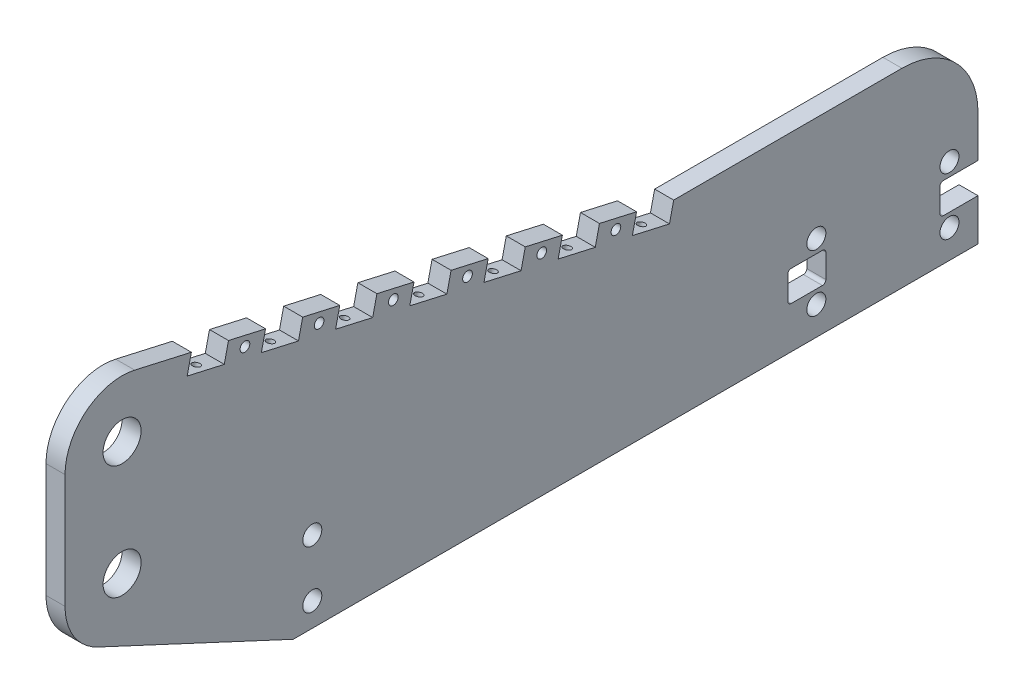
from build123d import *

# Parameters (mm, degrees)
SKETCH1_R           = 12.7
BOSS_EXTRUDE1_DEPTH = 12.7
SKETCH2_R           = 6.35
CUT_EXTRUDE1_DEPTH  = 13.7
SKETCH3_R           = 6.35
CUT_EXTRUDE2_DEPTH  = 13.7
SKETCH4_W           = 25.4
SKETCH4_H           = 20.32
CUT_EXTRUDE3_DEPTH  = 13.7
FILLET1_R           = 2.286
CUT_EXTRUDE4_DEPTH  = 13.7
SKETCH6_R           = 3.2385
CUT_EXTRUDE5_DEPTH  = 13.7
SKETCH7_R           = 2.5527
CUT_EXTRUDE6_DEPTH  = 25.4
SKETCH8_R           = 5.08
CUT_EXTRUDE7_DEPTH  = 6.35
FILLET2_R           = 50.8
CUT_EXTRUDE9_DEPTH  = 6.35
BOSS_EXTRUDE2_DEPTH = 3.81


with BuildPart() as part:
    # Sketch1 → Boss-Extrude1 (new body)
    with BuildSketch(Plane(origin=(0, 0, 0), x_dir=(0, 0, -1), z_dir=(1, 0, 0))):
        with BuildLine():
            ThreePointArc((8.42580134, 113.356639673), (-23.775901339, 105.971068431), (-38.1, 76.2))
            Line((-38.1, 76.2), (-38.1, 0))
            ThreePointArc((-38.1, 0), (-32.127559007, -20.479989069), (-16.082679671, -34.539215605))
            Line((-16.082679671, -34.539215605), (114.3, -95.25))
            Line((114.3, -95.25), (571.5, -95.25))
            Line((571.5, -95.25), (571.5, 31.75))
            Line((571.5, 31.75), (368.3, 31.75))
            Line((368.3, 31.75), (8.42580134, 113.356639673))
        make_face()
        with Locations((0, 76.2)):
            Circle(SKETCH1_R, mode=Mode.SUBTRACT)
        Circle(SKETCH1_R, mode=Mode.SUBTRACT)
    extrude(amount=BOSS_EXTRUDE1_DEPTH)

    # Sketch2 → Cut-Extrude1 (cut, through all)
    with BuildSketch(Plane(origin=(12.7, 0, 0), x_dir=(0, 0, -1), z_dir=(1, 0, 0))):
        with Locations((552.45, -38.1)):
            Circle(SKETCH2_R)
        with Locations((463.55, -38.1)):
            Circle(SKETCH2_R)
        with Locations((463.55, -76.2)):
            Circle(SKETCH2_R)
        with Locations((552.45, -76.2)):
            Circle(SKETCH2_R)
    extrude(amount=-CUT_EXTRUDE1_DEPTH, mode=Mode.SUBTRACT)

    # Sketch3 → Cut-Extrude2 (cut, through all)
    with BuildSketch(Plane(origin=(12.7, 0, 0), x_dir=(0, 0, -1), z_dir=(1, 0, 0))):
        with Locations((127, -41.275)):
            Circle(SKETCH3_R)
        with Locations((127, -79.375)):
            Circle(SKETCH3_R)
    extrude(amount=-CUT_EXTRUDE2_DEPTH, mode=Mode.SUBTRACT)

    # Sketch4 → Cut-Extrude3 (cut, through all)
    with BuildSketch(Plane(origin=(12.7, 0, 0), x_dir=(0, 0, -1), z_dir=(1, 0, 0))):
        with Locations((558.8, -57.15)):
            Rectangle(SKETCH4_W, SKETCH4_H)
        with Locations((457.2, -57.15)):
            Rectangle(SKETCH4_W, SKETCH4_H)
    extrude(amount=-CUT_EXTRUDE3_DEPTH, mode=Mode.SUBTRACT)

    # Fillet1
    fillet1_edges = [part.edges().sort_by_distance(p)[0] for p in [
        (6.35, -67.31, -546.1),
        (6.35, -46.99, -546.1),
        (6.35, -67.31, -444.5),
        (6.35, -46.99, -444.5),
        (6.35, -46.99, -469.9),
        (6.35, -67.31, -469.9),
    ]]
    fillet(fillet1_edges, radius=FILLET1_R)

    # Sketch5 → Cut-Extrude4 (cut, through all)
    with BuildSketch(Plane(origin=(12.7, 0, 0), x_dir=(0, 0, -1), z_dir=(1, 0, 0))):
        Polygon((368.3, 31.75), (343.528906885, 37.367200893), (340.720306438, 24.981654336), (365.491399553, 19.364453442), align=None)
        Polygon((293.986720654, 48.60160268), (291.178120208, 36.216056122), (315.949213323, 30.598855229), (318.757813769, 42.984401786), align=None)
        Polygon((244.444534424, 59.836004466), (241.635933977, 47.450457908), (266.407027092, 41.833257015), (269.215627539, 54.218803573), align=None)
        Polygon((194.902348193, 71.070406253), (192.093747747, 58.684859695), (216.864840862, 53.067658802), (219.673441308, 65.453205359), align=None)
        Polygon((145.360161963, 82.304808039), (142.551561516, 69.919261481), (167.322654631, 64.302060588), (170.131255078, 76.687607146), align=None)
        Polygon((95.817975732, 93.539209825), (93.009375285, 81.153663268), (117.780468401, 75.536462375), (120.589068847, 87.922008932), align=None)
        Polygon((46.275789502, 104.773611612), (43.467189055, 92.388065054), (68.23828217, 86.770864161), (71.046882617, 99.156410719), align=None)
    extrude(amount=-CUT_EXTRUDE4_DEPTH, mode=Mode.SUBTRACT)

    # Sketch6 → Cut-Extrude5 (cut, through all)
    with BuildSketch(Plane(origin=(12.7, 0, 0), x_dir=(0, 0, -1), z_dir=(1, 0, 0))):
        with Locations((329.739060104, 33.983028061)):
            Circle(SKETCH6_R)
        with Locations((280.196873873, 45.217429847)):
            Circle(SKETCH6_R)
        with Locations((230.654687643, 56.451831634)):
            Circle(SKETCH6_R)
        with Locations((181.112501412, 67.68623342)):
            Circle(SKETCH6_R)
        with Locations((131.570315182, 78.920635207)):
            Circle(SKETCH6_R)
        with Locations((82.028128951, 90.155036993)):
            Circle(SKETCH6_R)
    extrude(amount=-CUT_EXTRUDE5_DEPTH, mode=Mode.SUBTRACT)

    # Sketch7 → Cut-Extrude6 (cut)
    with BuildSketch(Plane(origin=(0, 97.244367225, -22.051555977), x_dir=(1, 0, 0), z_dir=(0, 0.975239886, -0.221149641))):
        with Locations((6.35, 339.459349055)):
            Circle(SKETCH7_R)
        with Locations((6.35, 288.659349055)):
            Circle(SKETCH7_R)
        with Locations((6.35, 237.859349055)):
            Circle(SKETCH7_R)
        with Locations((6.35, 187.059349055)):
            Circle(SKETCH7_R)
        with Locations((6.35, 136.259349055)):
            Circle(SKETCH7_R)
        with Locations((6.35, 85.459349055)):
            Circle(SKETCH7_R)
        with Locations((6.35, 34.659349055)):
            Circle(SKETCH7_R)
    extrude(amount=-CUT_EXTRUDE6_DEPTH, mode=Mode.SUBTRACT)

    # Sketch8 → Cut-Extrude7 (cut)
    with BuildSketch(Plane(origin=(0, 0, 0), x_dir=(0, 0, -1), z_dir=(1, 0, 0))):
        with Locations((82.028128951, 90.155036993)):
            Circle(SKETCH8_R)
        with Locations((131.570315182, 78.920635207)):
            Circle(SKETCH8_R)
        with Locations((181.112501412, 67.68623342)):
            Circle(SKETCH8_R)
        with Locations((230.654687643, 56.451831634)):
            Circle(SKETCH8_R)
        with Locations((280.196873873, 45.217429847)):
            Circle(SKETCH8_R)
        with Locations((329.739060104, 33.983028061)):
            Circle(SKETCH8_R)
    extrude(amount=CUT_EXTRUDE7_DEPTH, mode=Mode.SUBTRACT)

    # Fillet2
    fillet2_edges = [part.edges().sort_by_distance(p)[0] for p in [
        (6.35, 31.75, -571.5),
    ]]
    fillet(fillet2_edges, radius=FILLET2_R)

    # Sketch10 → Cut-Extrude9 (cut)
    with BuildSketch(Plane(origin=(0, 0, 0), x_dir=(0, 0, -1), z_dir=(1, 0, 0))):
        with BuildLine():
            Line((364.828417283, -6.530079852), (34.705160268, 68.3301068))
            ThreePointArc((34.705160268, 68.3301068), (28.264819732, 66.852992552), (25.4, 60.898778866))
            Line((25.4, 60.898778866), (25.4, 0))
            ThreePointArc((25.4, 0), (22.263812519, -12.226309833), (13.629712431, -21.43340708))
            ThreePointArc((13.629712431, -21.43340708), (10.114873073, -28.360761065), (14.502090227, -34.771272324))
            Line((14.502090227, -34.771272324), (99.851156833, -74.512814638))
            ThreePointArc((99.851156833, -74.512814638), (105.601486182, -74.791367757), (109.905494833, -70.967836798))
            ThreePointArc((109.905494833, -70.967836798), (111.566063693, -68.208258753), (113.667777257, -65.767857143))
            ThreePointArc((113.667777257, -65.767857143), (115.95488816, -60.325), (113.667777257, -54.882142857))
            ThreePointArc((113.667777257, -54.882142857), (127, -22.225), (140.332222743, -54.882142857))
            ThreePointArc((140.332222743, -54.882142857), (138.04511184, -60.325), (140.332222743, -65.767857143))
            ThreePointArc((140.332222743, -65.767857143), (143.883813818, -70.552339916), (145.783553311, -76.2))
            ThreePointArc((145.783553311, -76.2), (148.378285786, -80.749871133), (153.296974636, -82.55))
            Line((153.296974636, -82.55), (424.18, -82.55))
            ThreePointArc((424.18, -82.55), (429.568153673, -80.318153673), (431.8, -74.93))
            Line((431.8, -74.93), (431.8, -51.762101286))
            ThreePointArc((431.8, -51.762101286), (432.175808218, -49.398611193), (433.266164152, -47.268249446))
            Line((433.266164152, -47.268249446), (448.165410381, -26.8653704))
            ThreePointArc((448.165410381, -26.8653704), (454.922056846, -21.115857486), (463.55, -19.05))
            Line((463.55, -19.05), (550.212133098, -19.05))
            ThreePointArc((550.212133098, -19.05), (556.236272041, -16.09627796), (557.590166373, -9.525))
            ThreePointArc((557.590166373, -9.525), (544.0313898, 11.070694713), (520.7, 19.05))
            Line((520.7, 19.05), (384.528047587, 19.05))
            ThreePointArc((384.528047587, 19.05), (379.772867319, 17.384213686), (377.096719652, 13.115160268))
            Line((377.096719652, 13.115160268), (373.944905486, -0.783912185))
            ThreePointArc((373.944905486, -0.783912185), (370.576731674, -5.545082546), (364.828417283, -6.530079852))
        make_face()
    extrude(amount=CUT_EXTRUDE9_DEPTH, mode=Mode.SUBTRACT)

    # Sketch11 → Boss-Extrude2 (add)
    with BuildSketch(Plane.ZY.offset(-6.35)):
        with BuildLine():
            Line((-404.656786087, 7.360531239), (-448.490480082, -20.854613376))
            ThreePointArc((-448.490480082, -20.854613376), (-451.620677438, -21.857731425), (-454.833066892, -21.161358461))
            ThreePointArc((-454.833066892, -21.161358461), (-451.166349993, -23.624237066), (-448.165410381, -26.8653704))
            Line((-448.165410381, -26.8653704), (-439.780595822, -38.347451751))
            ThreePointArc((-439.780595822, -38.347451751), (-440.895133763, -33.440350541), (-438.089341724, -29.263106457))
            Line((-438.089341724, -29.263106457), (-385.604431522, 4.52070678))
            ThreePointArc((-385.604431522, 4.52070678), (-380.822199818, 5.387097895), (-376.828020319, 2.618180461))
            Line((-376.828020319, 2.618180461), (-328.306156472, -72.763057558))
            ThreePointArc((-328.306156472, -72.763057558), (-328.071260494, -79.241209915), (-333.645625233, -82.55))
            Line((-333.645625233, -82.55), (-275.410766677, -82.55))
            ThreePointArc((-275.410766677, -82.55), (-281.216978966, -78.771069592), (-280.112554351, -71.932015386))
            Line((-280.112554351, -71.932015386), (-188.961118149, 28.484161784))
            ThreePointArc((-188.961118149, 28.484161784), (-183.735577608, 30.544540539), (-178.919861714, 27.653119612))
            Line((-178.919861714, 27.653119612), (-144.245386624, -26.215480082))
            ThreePointArc((-144.245386624, -26.215480082), (-143.242268575, -29.345677438), (-143.938641539, -32.558066892))
            ThreePointArc((-143.938641539, -32.558066892), (-137.310827325, -25.256593716), (-127.920235255, -22.247239568))
            ThreePointArc((-127.920235255, -22.247239568), (-131.13262471, -21.550866603), (-133.566449102, -19.341595198))
            Line((-133.566449102, -19.341595198), (-165.311440029, 29.975898552))
            ThreePointArc((-165.311440029, 29.975898552), (-165.850105431, 35.81493149), (-161.376271491, 39.605614272))
            Line((-161.376271491, 39.605614272), (-224.642275715, 25.259139783))
            ThreePointArc((-224.642275715, 25.259139783), (-217.753887619, 22.267503834), (-218.536187818, 14.79838189))
            Line((-218.536187818, 14.79838189), (-301.340728215, -76.422511006))
            ThreePointArc((-301.340728215, -76.422511006), (-306.566268756, -78.48288976), (-311.381984651, -75.591468833))
            Line((-311.381984651, -75.591468833), (-352.073502931, -12.375079731))
            ThreePointArc((-352.073502931, -12.375079731), (-352.612168333, -6.536046792), (-348.138334393, -2.74536401))
            Line((-348.138334393, -2.74536401), (-364.828417283, -6.530079852))
            ThreePointArc((-364.828417283, -6.530079852), (-370.576731674, -5.545082546), (-373.944905486, -0.783912185))
            Line((-373.944905486, -0.783912185), (-377.096719652, 13.115160268))
            ThreePointArc((-377.096719652, 13.115160268), (-379.772867319, 17.384213686), (-384.528047587, 19.05))
            Line((-384.528047587, 19.05), (-408.093728528, 19.05))
            ThreePointArc((-408.093728528, 19.05), (-402.001597266, 14.491210954), (-404.656786087, 7.360531239))
        make_face()
        with BuildLine():
            ThreePointArc((-121.356860929, -23.080014938), (-113.015405676, -28.33925025), (-108.421111179, -37.064609262))
            ThreePointArc((-108.421111179, -37.064609262), (-108.293143259, -33.780099325), (-106.540064822, -30.999614241))
            Line((-106.540064822, -30.999614241), (-36.061916583, 34.19267288))
            ThreePointArc((-36.061916583, 34.19267288), (-29.206200706, 35.349352946), (-25.4, 29.531141438))
            Line((-25.4, 29.531141438), (-25.4, 60.898778866))
            ThreePointArc((-25.4, 60.898778866), (-28.264819732, 66.852992552), (-34.705160268, 68.3301068))
            Line((-34.705160268, 68.3301068), (-35.506436314, 68.148405956))
            ThreePointArc((-35.506436314, 68.148405956), (-28.483636205, 64.914510681), (-29.790219508, 57.294101236))
            Line((-29.790219508, 57.294101236), (-115.163897988, -21.676551358))
            ThreePointArc((-115.163897988, -21.676551358), (-118.072350992, -23.207982857), (-121.356860929, -23.080014938))
        make_face()
    extrude(amount=BOSS_EXTRUDE2_DEPTH)


solid = part.part
